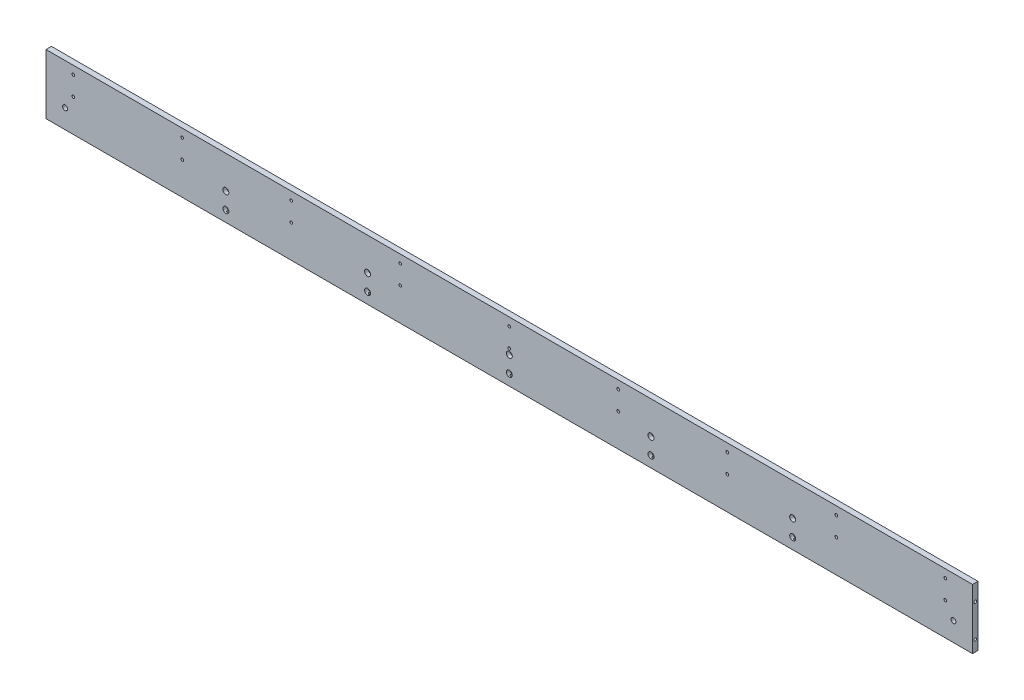
from build123d import *

# Parameters (mm, degrees)
SKETCH_1_W                  = 1700
SKETCH_1_H                  = 100
EXTRUDE_1_DEPTH             = 5
HOLE_WIZARD_M6_1_AT_2_COUNT = 2
HOLE_WIZARD_M6_1_AT_2_PITCH = 60
HOLE_WIZARD_M6_2_D          = 5
HOLE_WIZARD_M6_2_DEPTH      = 15
HOLE_WIZARD_M6_2_TIP        = 1.502151548
HOLE_WIZARD_2_D             = 6.6
HOLE_WIZARD_2_CBORE_D       = 11
HOLE_WIZARD_2_CBORE_DEPTH   = 6.8
PATTERN_LINEAR_1_COUNT      = 2
PATTERN_LINEAR_1_PITCH      = 30
HOLE_WIZARD_M6_3_D          = 5
PATTERN_LINEAR_2_COUNT      = 9
PATTERN_LINEAR_2_PITCH      = 200
HOLE_WIZARD_9_0_9_1_D       = 9
SKETCH_25_W                 = 1700
SKETCH_25_H                 = 10
EXTRUDE_2_DEPTH             = 10


with BuildPart() as part:
    # 草图1 → 凸台-拉伸1 (new body, symmetric)
    with BuildSketch(Plane.XY):
        Rectangle(SKETCH_1_W, SKETCH_1_H)
    extrude(amount=EXTRUDE_1_DEPTH, both=True)

    # 草图5 → M6 螺纹孔1 (revolve, cut)
    with BuildSketch(Plane(origin=(-850, 30, 0), x_dir=(0, 0, 1), z_dir=(0, 1, 0))):
        Polygon((0, 0), (0, 16.502151548), (2.5, 15), (2.5, 0), align=None)
    hole_wizard_m6_1 = revolve(axis=Axis((-856.35, 30, 0), (1, 0, 0)), mode=Mode.SUBTRACT)

    # M6 螺纹孔1 at 2: M6 螺纹孔1 ×2
    with Locations(*[(0, -i * HOLE_WIZARD_M6_1_AT_2_PITCH, 0) for i in range(1, HOLE_WIZARD_M6_1_AT_2_COUNT)]):
        add(hole_wizard_m6_1, mode=Mode.SUBTRACT)

    # 镜向1: M6 螺纹孔1 across plane
    add(hole_wizard_m6_1.mirror(Plane(origin=(0, 0, 0), x_dir=(0, 0, 1), z_dir=(1, 0, 0))), mode=Mode.SUBTRACT)

    # 镜向1 copy 1 sketch → 镜向1 copy 1 (revolve, cut)
    with BuildSketch(Plane(origin=(850, -30, 0), x_dir=(0, 0, 1), z_dir=(0, 1, 0))):
        Polygon((0, 0), (0, -16.502151548), (2.5, -15), (2.5, 0), align=None)
    revolve(axis=Axis((856.35, -30, 0), (1, 0, 0)), mode=Mode.SUBTRACT)

    # M6 螺纹孔2
    with Locations(Plane(origin=(-520, -50, 0), x_dir=(0, 0, -1), z_dir=(0, -1, 0))):
        with Locations((0, 0), (0, 260), (0, 520), (0, 780), (0, 1040)):
            Hole(HOLE_WIZARD_M6_2_D / 2, depth=HOLE_WIZARD_M6_2_DEPTH)
            with Locations((0, 0, -(HOLE_WIZARD_M6_2_DEPTH + HOLE_WIZARD_M6_2_TIP / 2))):  # 118° drill point
                Cone(0, HOLE_WIZARD_M6_2_D / 2, HOLE_WIZARD_M6_2_TIP, mode=Mode.SUBTRACT)

    # 打孔尺寸(%根据)内六角圆柱头螺钉的类型2 (through all)
    with Locations(Plane(origin=(520, -30, 5), x_dir=(1, 0, 0), z_dir=(0, 0, 1))):
        with Locations((0, 0), (-260, 0), (-520, 0), (-780, 0), (-1040, 0)):
            hole_wizard_2 = CounterBoreHole(HOLE_WIZARD_2_D / 2, HOLE_WIZARD_2_CBORE_D / 2, HOLE_WIZARD_2_CBORE_DEPTH)

    # 阵列(线性)1: 打孔尺寸(%根据)内六角圆柱头螺钉的类型2 ×2
    with Locations(*[(0, i * PATTERN_LINEAR_1_PITCH, 0) for i in range(1, PATTERN_LINEAR_1_COUNT)]):
        add(hole_wizard_2, mode=Mode.SUBTRACT)

    # M6 螺纹孔3 (through all)
    with Locations(Plane(origin=(-800, 45, 5), x_dir=(1, 0, 0), z_dir=(0, 0, 1))):
        with Locations((0, 0), (0, -35)):
            hole_wizard_m6_3 = Hole(HOLE_WIZARD_M6_3_D / 2)

    # 阵列(线性)2: M6 螺纹孔3 ×9
    with Locations(*[(i * PATTERN_LINEAR_2_PITCH, 0, 0) for i in range(1, PATTERN_LINEAR_2_COUNT)]):
        add(hole_wizard_m6_3, mode=Mode.SUBTRACT)

    # Ø9.0 (9) 直径孔1 (through all)
    with Locations(Plane(origin=(815, -15, 5), x_dir=(1, 0, 0), z_dir=(0, 0, 1))):
        with Locations((0, 0)):
            hole_wizard_9_0_9_1 = Hole(HOLE_WIZARD_9_0_9_1_D / 2)

    # 镜向2: Ø9.0 (9) 直径孔1 across plane
    add(hole_wizard_9_0_9_1.mirror(Plane(origin=(0, 0, 0), x_dir=(0, 0, 1), z_dir=(1, 0, 0))), mode=Mode.SUBTRACT)

    # 草图25 → 凸台-拉伸2 (add)
    with BuildSketch(Plane(origin=(0, 50, 0), x_dir=(1, 0, 0), z_dir=(0, 1, 0))):
        Rectangle(SKETCH_25_W, SKETCH_25_H)
    extrude(amount=EXTRUDE_2_DEPTH)


solid = part.part
